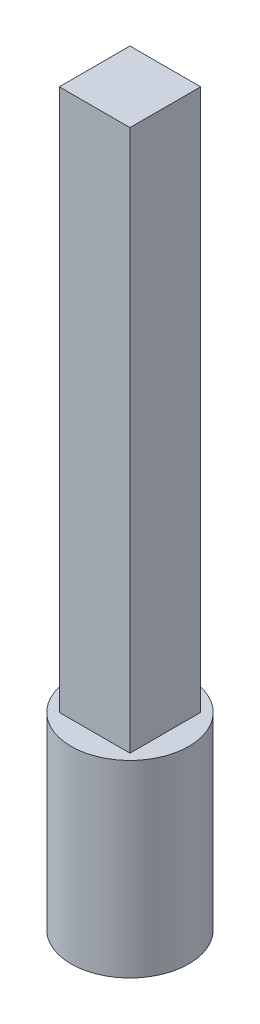
from build123d import *

# Parameters (mm, degrees)
SKETCH_1_R      = 25
EXTRUDE_1_DEPTH = 80
SKETCH_2_W      = 30
SKETCH_2_H      = 30
EXTRUDE_2_DEPTH = 230


with BuildPart() as part:
    # 草图1 → 凸台-拉伸1 (new body)
    with BuildSketch(Plane(origin=(0, 0, 0), x_dir=(1, 0, 0), z_dir=(0, 1, 0))):
        Circle(SKETCH_1_R)
    extrude(amount=EXTRUDE_1_DEPTH)

    # 草图2 → 凸台-拉伸2 (add)
    with BuildSketch(Plane(origin=(0, 80, 0), x_dir=(1, 0, 0), z_dir=(0, 1, 0))):
        Rectangle(SKETCH_2_W, SKETCH_2_H)
    extrude(amount=EXTRUDE_2_DEPTH)


solid = part.part
